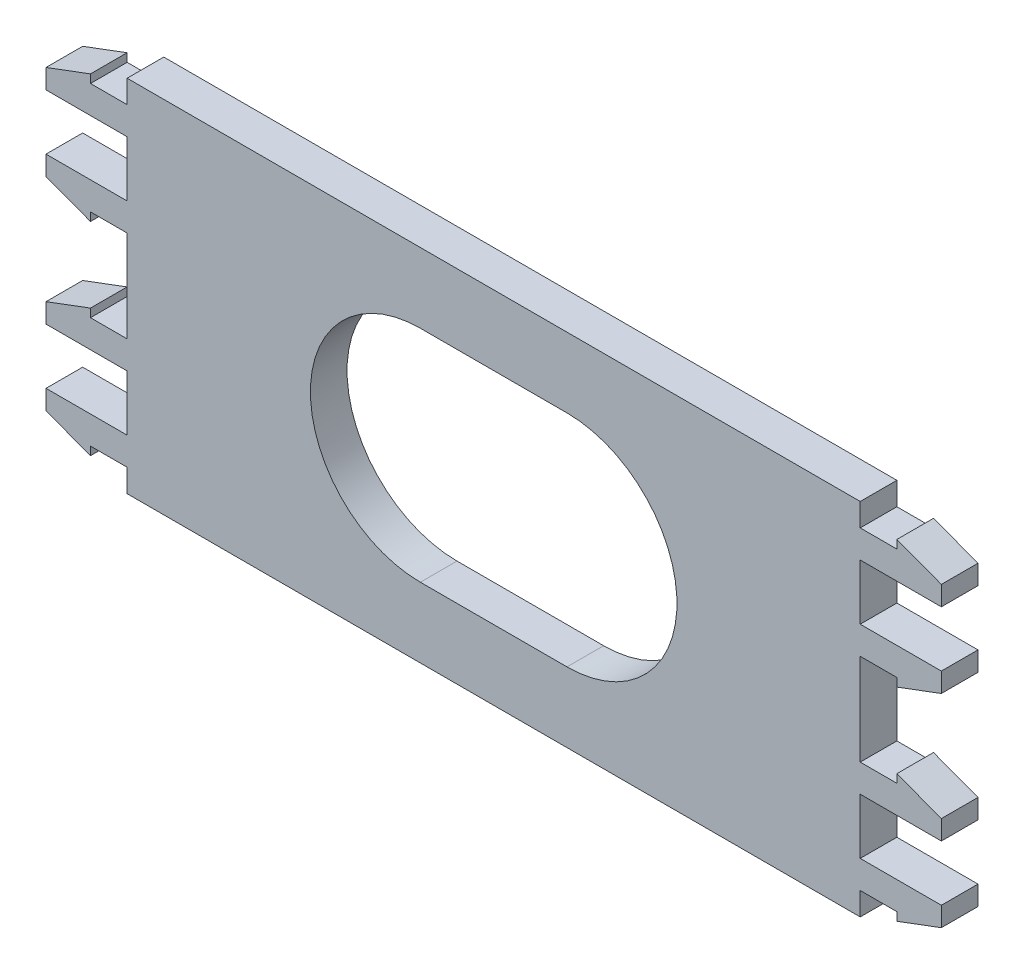
from build123d import *

# Parameters (mm, degrees)
ESTRUSIONE_ESTRUSIONE1_DEPTH = 6


with BuildPart() as part:
    # Schizzo1 → Estrusione-Estrusione1 (new body)
    with BuildSketch(Plane.XY):
        Polygon((6, -115.594034624), (0, -115.594034624), (0, -100.594034624), (6, -100.594034624), (6, -101.959034624), (13.28, -99.229034624), (13.28, -96.044034624), (6, -96.044034624), (0, -96.044034624), (0, -86.944034624), (6, -86.944034624), (13.28, -86.944034624), (13.28, -83.759034624), (6, -81.029034624), (6, -82.394034624), (0, -82.394034624), (0, -78.644034624), (-120, -78.644034624), (-120, -82.394034624), (-126, -82.394034624), (-126, -81.029034624), (-133.28, -83.759034624), (-133.28, -86.944034624), (-126, -86.944034624), (-120, -86.944034624), (-120, -96.044034624), (-126, -96.044034624), (-133.28, -96.044034624), (-133.28, -99.229034624), (-126, -101.959034624), (-126, -100.594034624), (-120, -100.594034624), (-120, -115.594034624), (-126, -115.594034624), (-126, -114.229034624), (-133.28, -116.959034624), (-133.28, -120.144034624), (-126, -120.144034624), (-120, -120.144034624), (-120, -129.244034624), (-126, -129.244034624), (-133.28, -129.244034624), (-133.28, -132.429034624), (-126, -135.159034624), (-126, -133.794034624), (-120, -133.794034624), (-120, -137.544034624), (0, -137.544034624), (0, -133.794034624), (6, -133.794034624), (6, -135.159034624), (13.28, -132.429034624), (13.28, -129.244034624), (6, -129.244034624), (0, -129.244034624), (0, -120.144034624), (6, -120.144034624), (13.28, -120.144034624), (13.28, -116.959034624), (6, -114.229034624), align=None)
        with BuildLine():
            Line((-72, -90.094034624), (-48, -90.094034624))
            ThreePointArc((-48, -90.094034624), (-30, -108.094034624), (-48, -126.094034624))
            Line((-48, -126.094034624), (-72, -126.094034624))
            ThreePointArc((-72, -126.094034624), (-90, -108.094034624), (-72, -90.094034624))
        make_face(mode=Mode.SUBTRACT)
    extrude(amount=ESTRUSIONE_ESTRUSIONE1_DEPTH)


solid = part.part
